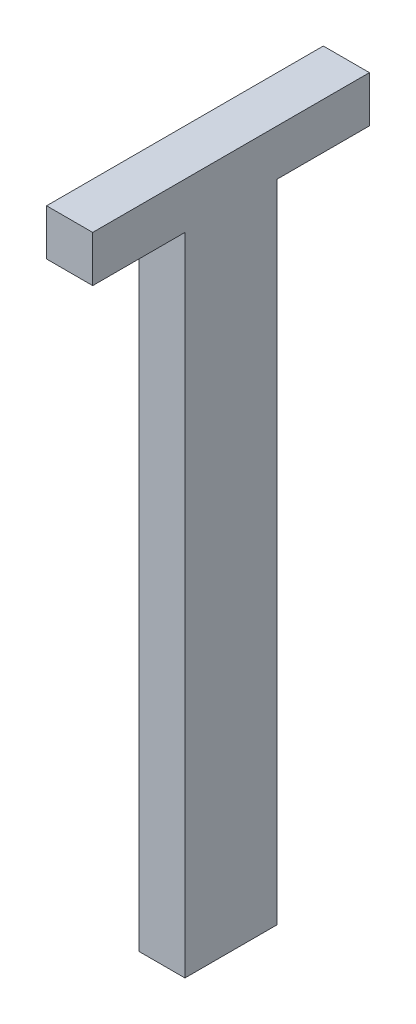
from build123d import *

# Parameters (mm, degrees)
SKETCH_1_W      = 5
SKETCH_1_H      = 10
EXTRUDE_1_DEPTH = 70
SKETCH_2_W      = 5
SKETCH_2_H      = 10
EXTRUDE_2_DEPTH = 5


with BuildPart() as part:
    # 草图1 → 凸台-拉伸1 (new body)
    with BuildSketch(Plane(origin=(0, 0, 0), x_dir=(1, 0, 0), z_dir=(0, 1, 0))):
        with Locations((2.5, 5)):
            Rectangle(SKETCH_1_W, SKETCH_1_H)
    extrude(amount=EXTRUDE_1_DEPTH)

    # 草图2 → 凸台-拉伸2 (add)
    with BuildSketch(Plane(origin=(0, 70, 0), x_dir=(1, 0, 0), z_dir=(0, 1, 0))):
        with Locations((2.5, 15)):
            Rectangle(SKETCH_2_W, SKETCH_2_H)
        with Locations((2.5, 5)):
            Rectangle(SKETCH_2_W, SKETCH_2_H)
        with Locations((2.5, -5)):
            Rectangle(SKETCH_2_W, SKETCH_2_H)
    extrude(amount=EXTRUDE_2_DEPTH)


solid = part.part
